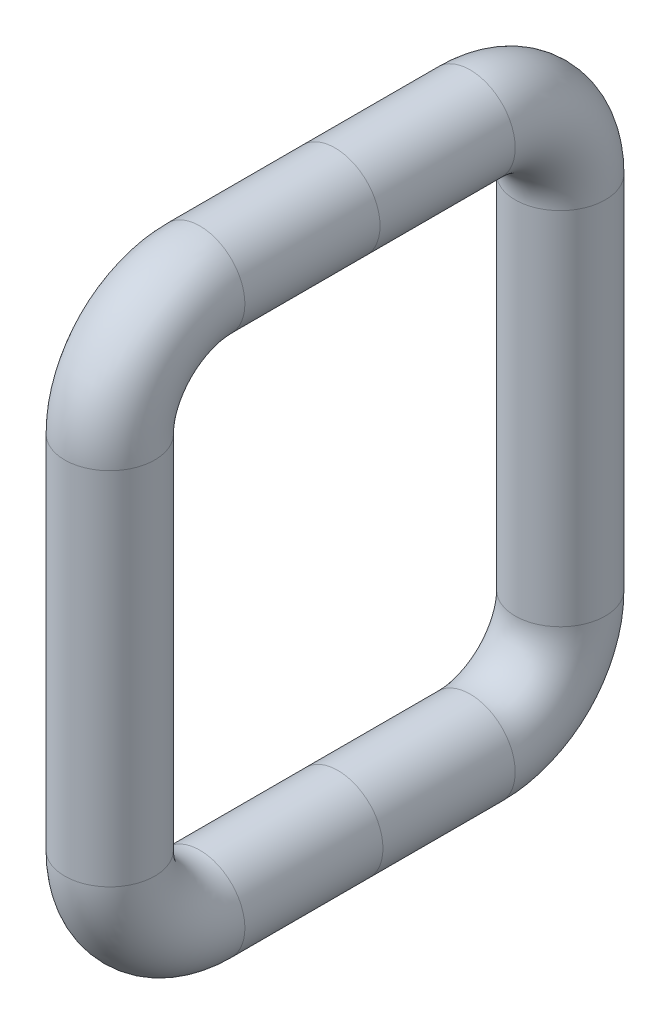
from build123d import *

# Parameters (mm, degrees)
SKETCH1_R = 25.4


with BuildPart() as part:
    # Sweep1: sweep along a curve in space
    with BuildLine() as sweep1_path:
        Line((0, 36.968559092, 0), (0, 36.968559092, -76.2))
        ThreePointArc((0, 36.968559092, -76.2), (0, 22.089583576, -112.121024484), (0, -13.831440908, -127))
        Line((0, -13.831440908, -127), (0, -217.031440908, -127))
        ThreePointArc((0, -217.031440908, -127), (0, -252.952465392, -112.121024484), (0, -267.831440908, -76.2))
        Line((0, -267.831440908, -76.2), (0, -267.831440908, -1.63913495))
        Line((0, -267.831440908, -1.63913495), (0, -267.831440908, 76.2))
        ThreePointArc((0, -267.831440908, 76.2), (0, -252.952465392, 112.121024484), (0, -217.031440908, 127))
        Line((0, -217.031440908, 127), (0, -13.831440908, 127))
        ThreePointArc((0, 36.968559092, 76.2), (0, 22.089583576, 112.121024484), (0, -13.831440908, 127))
        Line((0, 36.968559092, 0), (0, 36.968559092, 76.2))
    # Sketch1 → Sweep1 (sweep)
    with BuildSketch(Plane.XY):
        with Locations((0, 36.968559092)):
            Circle(SKETCH1_R)
    sweep(path=sweep1_path.line)


solid = part.part
